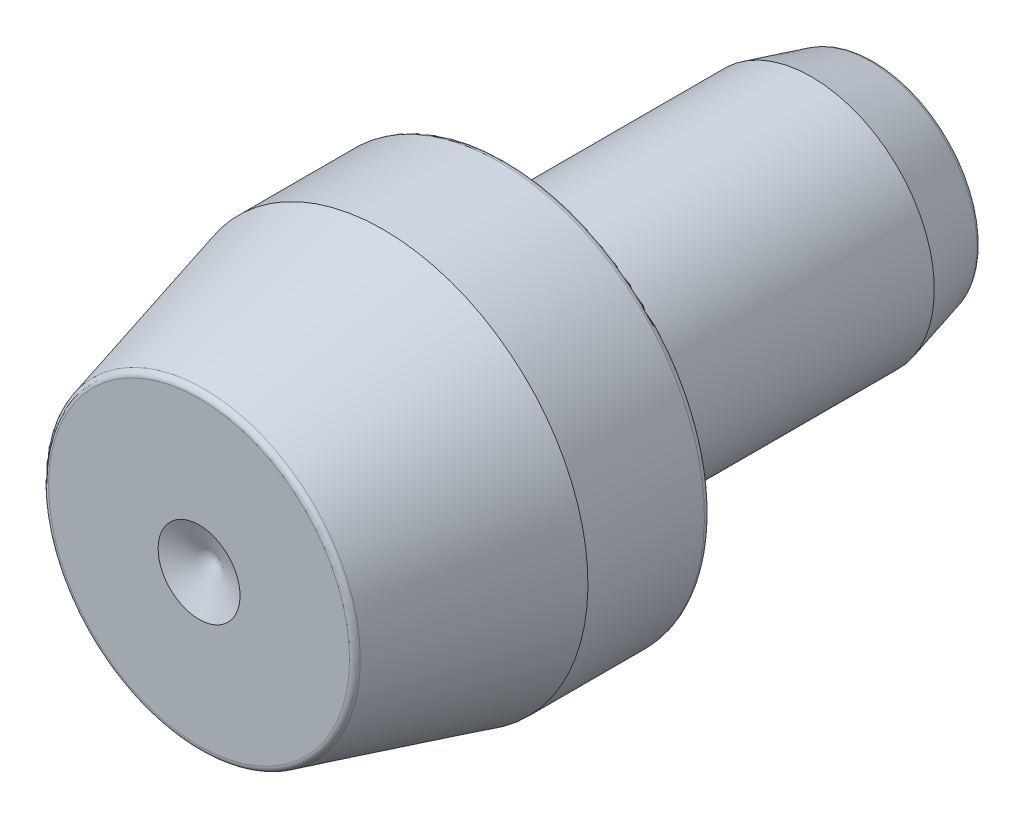
from build123d import *


with BuildPart() as part:
    # Sketch1 → Revolve1 (revolve)
    with BuildSketch(Plane(origin=(0, 0, 0), x_dir=(0, 0, -1), z_dir=(1, 0, 0))):
        with BuildLine():
            Line((-16.5, 2), (-16.5, 7.352504219))
            ThreePointArc((-16.5, 7.352504219), (-16.436456152, 7.539698359), (-16.272086856, 7.649526411))
            Line((-16.272086856, 7.649526411), (-7.5, 10))
            Line((-7.5, 10), (-1.8075, 10))
            ThreePointArc((-1.8075, 10), (-1.590064665, 9.909935335), (-1.5, 9.6925))
            Line((-1.5, 9.6925), (-1.5, 6.9225))
            ThreePointArc((-1.5, 6.9225), (-1.717435335, 6.832435335), (-1.8075, 6.615))
            Line((-1.8075, 6.615), (-1.8075, 6))
            ThreePointArc((-1.8075, 6), (-1.717435335, 5.782564665), (-1.5, 5.6925))
            Line((-1.5, 5.6925), (0.0375, 5.6925))
            Line((0.0375, 5.6925), (0.345, 6))
            Line((0.345, 6), (13.425, 6))
            Line((13.425, 6), (16.272086856, 5.237125376))
            ThreePointArc((16.272086856, 5.237125376), (16.436456152, 5.127297324), (16.5, 4.940103184))
            Line((16.5, 4.940103184), (16.5, 0))
            Line((16.5, 0), (-15.671572875, 0))
            Line((-15.671572875, 0), (-16.5, 2))
        make_face()
    revolve(axis=Axis((0, 0, -16.5), (0, 0, 1)))


solid = part.part
